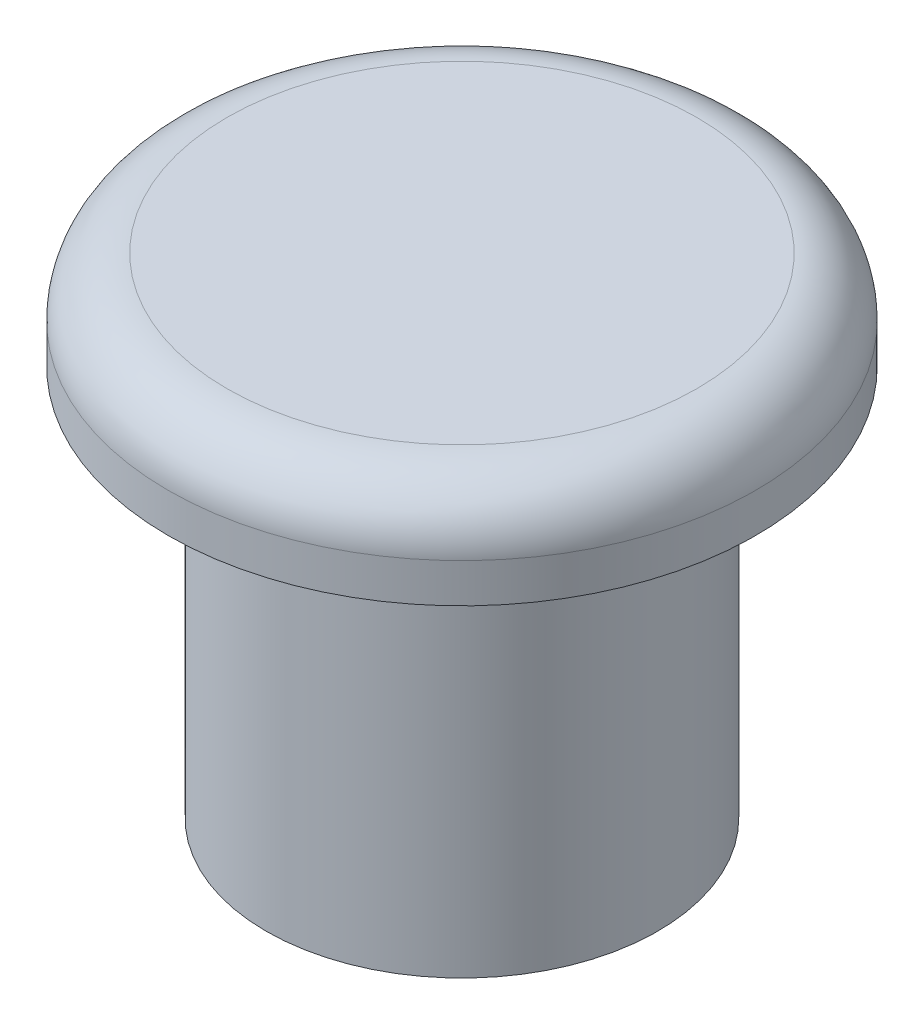
from build123d import *

# Parameters (mm, degrees)
SKETCH1_R           = 1.5
BOSS_EXTRUDE1_DEPTH = 0.5
SKETCH1_3_R         = 1
BOSS_EXTRUDE2_DEPTH = 2
FILLET1_R           = 0.3


with BuildPart() as part:
    # Sketch1 → Boss-Extrude1 (new body)
    with BuildSketch(Plane(origin=(0, 0, 0), x_dir=(1, 0, 0), z_dir=(0, 1, 0))):
        Circle(SKETCH1_R)
    extrude(amount=BOSS_EXTRUDE1_DEPTH)

    # Sketch1_3 → Boss-Extrude2 (add)
    with BuildSketch(Plane(origin=(0, 0, 0), x_dir=(1, 0, 0), z_dir=(0, 1, 0))):
        Circle(SKETCH1_3_R)
    extrude(amount=-BOSS_EXTRUDE2_DEPTH)

    # Fillet1
    fillet1_edges = [part.edges().sort_by_distance(p)[0] for p in [
        (-1.5, 0.5, 0),
    ]]
    fillet(fillet1_edges, radius=FILLET1_R)


solid = part.part
